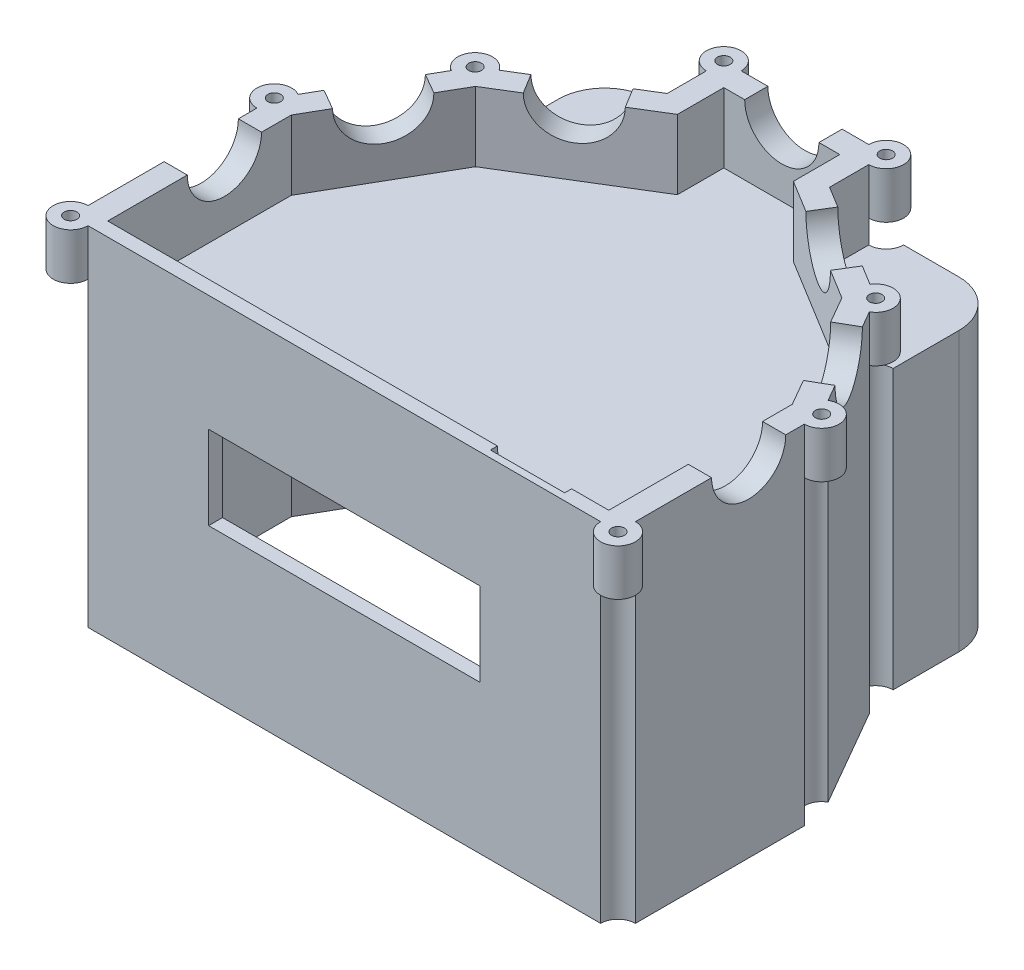
from build123d import *

# Parameters (mm, degrees)
BOSS_EXTRUDE2_DEPTH  = 15
BOSS_EXTRUDE3_DEPTH  = 5
SKETCH7_R            = 3.75
BOSS_EXTRUDE9_DEPTH  = 10
SKETCH9_R            = 1.375
CUT_EXTRUDE5_DEPTH   = 21
CUT_EXTRUDE9_REACH   = 131.287
SKETCH14_R           = 8
CUT_EXTRUDE11_REACH  = 105.053
SKETCH16_R           = 8
CUT_EXTRUDE12_REACH  = 131.287
SKETCH17_R           = 8
CUT_EXTRUDE13_REACH  = 121.393
SKETCH19_R           = 8
CUT_EXTRUDE14_REACH  = 121.393
SKETCH20_R           = 8
BOSS_EXTRUDE11_DEPTH = 55
FILLET1_R            = 10
SKETCH25_R           = 4
SKETCH25_R_2         = 1.4
BOSS_EXTRUDE12_DEPTH = 5
SKETCH24_R           = 3.75
CUT_EXTRUDE15_DEPTH  = 65
CUT_EXTRUDE17_REACH  = 105.053
SKETCH26_W           = 58.5
SKETCH26_H           = 18
BOSS_EXTRUDE13_REACH = 77
SKETCH27_R           = 4
SKETCH28_R           = 1.375
CUT_EXTRUDE18_DEPTH  = 25
SKETCH30_R           = 8
CUT_EXTRUDE19_DEPTH  = 122.75
SKETCH31_R           = 8
CUT_EXTRUDE20_DEPTH  = 1.5
SKETCH33_W           = 27
SKETCH33_H           = 4
CUT_EXTRUDE21_DEPTH  = 40
SKETCH35_R           = 1.25
SKETCH35_W           = 9
SKETCH35_H           = 9
CUT_EXTRUDE22_DEPTH  = 7.75


with BuildPart() as part:
    # Sketch1 → Boss-Extrude2 (new body)
    with BuildSketch(Plane(origin=(0, 0, 0), x_dir=(1, 0, 0), z_dir=(0, 1, 0))):
        Polygon((-43.178681761, 29.873916914), (-17.5, 45.604089113), (-17.5, 57.803420417), (17.5, 57.803420417), (17.5, 45.604089113), (43.178681761, 29.873916914), (59, 2.406681305), (59, -41.5), (-59, -41.5), (-59, 2.406681305), align=None)
        Polygon((39.481402229, 26.275231503), (12.5, 42.803420417), (12.5, 52.803420417), (-12.5, 52.803420417), (-12.5, 42.803420417), (-39.481402229, 26.275231503), (-54, 1.069636136), (-54, -38.5), (54, -38.5), (54, 1.069636136), align=None, mode=Mode.SUBTRACT)
    extrude(amount=BOSS_EXTRUDE2_DEPTH)

    # Sketch2 → Boss-Extrude3 (add)
    with BuildSketch(Plane.XZ):
        Polygon((-59, -2.406681305), (-59, 41.5), (59, 41.5), (59, -2.406681305), (43.178681761, -29.873916914), (43.178681761, -57.803420417), (-43.178681761, -57.803420417), (-43.178681761, -29.873916914), align=None)
    extrude(amount=BOSS_EXTRUDE3_DEPTH)

    # Sketch7 → Boss-Extrude9 (add)
    with BuildSketch(Plane(origin=(0, 15, 0), x_dir=(1, 0, 0), z_dir=(0, 1, 0))):
        with Locations((-59, -41.5)):
            Circle(SKETCH7_R)
        with Locations((-59, 2.406681305)):
            Circle(SKETCH7_R)
        with Locations((-43.178681761, 29.873916914)):
            Circle(SKETCH7_R)
        with Locations((-17.5, 57.803420417)):
            Circle(SKETCH7_R)
        with Locations((17.5, 57.803420417)):
            Circle(SKETCH7_R)
        with Locations((43.178681761, 29.873916914)):
            Circle(SKETCH7_R)
        with Locations((59, 2.406681305)):
            Circle(SKETCH7_R)
        with Locations((59, -41.5)):
            Circle(SKETCH7_R)
    extrude(amount=-BOSS_EXTRUDE9_DEPTH)

    # Sketch9 → Cut-Extrude5 (cut, through all)
    with BuildSketch(Plane(origin=(0, 15, 0), x_dir=(1, 0, 0), z_dir=(0, 1, 0))):
        with Locations((-59, -41.5)):
            Circle(SKETCH9_R)
        with Locations((-59, 2.406681305)):
            Circle(SKETCH9_R)
        with Locations((-17.5, 57.803420417)):
            Circle(SKETCH9_R)
        with Locations((43.178681761, 29.873916914)):
            Circle(SKETCH9_R)
        with Locations((17.5, 57.803420417)):
            Circle(SKETCH9_R)
        with Locations((-43.178681761, 29.873916914)):
            Circle(SKETCH9_R)
        with Locations((59, 2.406681305)):
            Circle(SKETCH9_R)
        with Locations((59, -41.5)):
            Circle(SKETCH9_R)
    extrude(amount=-CUT_EXTRUDE5_DEPTH, mode=Mode.SUBTRACT)

    # Sketch14 → Cut-Extrude9 (cut, up to next)
    with BuildSketch(Plane(origin=(-45.342387005, 0, -26.117529435), x_dir=(-0.499126718, 0, 0.866529006), z_dir=(-0.866529006, 0, -0.499126718)), mode=Mode.PRIVATE) as cut_extrude9_sk1:
        with Locations((11.514017709, 15)):
            Circle(SKETCH14_R)
    cut_extrude9_tool1 = extrude(cut_extrude9_sk1.sketch, amount=-CUT_EXTRUDE9_REACH, mode=Mode.PRIVATE) & part.part
    add(cut_extrude9_tool1.solids().sort_by_distance((-51.089341, 15, -16.140299))[0], mode=Mode.SUBTRACT)

    # Sketch16 → Cut-Extrude11 (cut, up to next)
    with BuildSketch(Plane(origin=(0, 0, -57.803420417), x_dir=(-1, 0, 0), z_dir=(0, 0, -1)), mode=Mode.PRIVATE) as cut_extrude11_sk1:
        with Locations((0, 15)):
            Circle(SKETCH16_R)
    cut_extrude11_tool1 = extrude(cut_extrude11_sk1.sketch, amount=-CUT_EXTRUDE11_REACH, mode=Mode.PRIVATE) & part.part
    add(cut_extrude11_tool1.solids().sort_by_distance((0, 15, -57.80342))[0], mode=Mode.SUBTRACT)

    # Sketch17 → Cut-Extrude12 (cut, up to next)
    with BuildSketch(Plane(origin=(45.342387005, 0, -26.117529435), x_dir=(-0.499126718, 0, -0.866529006), z_dir=(0.866529006, 0, -0.499126718)), mode=Mode.PRIVATE) as cut_extrude12_sk1:
        with Locations((-11.514017709, 15)):
            Circle(SKETCH17_R)
    cut_extrude12_tool1 = extrude(cut_extrude12_sk1.sketch, amount=-CUT_EXTRUDE12_REACH, mode=Mode.PRIVATE) & part.part
    add(cut_extrude12_tool1.solids().sort_by_distance((51.089341, 15, -16.140299))[0], mode=Mode.SUBTRACT)

    # Sketch19 → Cut-Extrude13 (cut, up to next)
    with BuildSketch(Plane(origin=(-25.088449392, 0, -40.955578852), x_dir=(-0.852725133, 0, 0.522359882), z_dir=(-0.522359882, 0, -0.852725133)), mode=Mode.PRIVATE) as cut_extrude13_sk1:
        with Locations((4.464611438, 15)):
            Circle(SKETCH19_R)
    cut_extrude13_tool1 = extrude(cut_extrude13_sk1.sketch, amount=-CUT_EXTRUDE13_REACH, mode=Mode.PRIVATE) & part.part
    add(cut_extrude13_tool1.solids().sort_by_distance((-28.895536, 15, -38.623445))[0], mode=Mode.SUBTRACT)

    # Sketch20 → Cut-Extrude14 (cut, up to next)
    with BuildSketch(Plane(origin=(25.088449392, 0, -40.955578852), x_dir=(-0.852725133, 0, -0.522359882), z_dir=(0.522359882, 0, -0.852725133)), mode=Mode.PRIVATE) as cut_extrude14_sk1:
        with Locations((-4.464611438, 15)):
            Circle(SKETCH20_R)
    cut_extrude14_tool1 = extrude(cut_extrude14_sk1.sketch, amount=-CUT_EXTRUDE14_REACH, mode=Mode.PRIVATE) & part.part
    add(cut_extrude14_tool1.solids().sort_by_distance((28.895536, 15, -38.623445))[0], mode=Mode.SUBTRACT)

    # Sketch21 → Boss-Extrude11 (add)
    with BuildSketch(Plane.XZ.offset(5)):
        Polygon((59, 41.5), (59, -2.406681305), (43.178681761, -29.873916914), (43.178681761, -57.803420417), (-43.178681761, -57.803420417), (-43.178681761, -29.873916914), (-59, -2.406681305), (-59, 41.5), align=None)
        Polygon((54, 38.5), (-54, 38.5), (-54, -1.069636136), (-38.178681761, -28.536871745), (-38.178681761, -52.803420417), (38.178681761, -52.803420417), (38.178681761, -28.536871745), (54, -1.069636136), align=None, mode=Mode.SUBTRACT)
    extrude(amount=BOSS_EXTRUDE11_DEPTH)

    # Fillet1
    fillet1_edges = [part.edges().sort_by_distance(p)[0] for p in [
        (43.178681761, -30, -57.803420417),
        (-43.178681761, -30, -57.803420417),
    ]]
    fillet(fillet1_edges, radius=FILLET1_R)

    # Sketch25 → Boss-Extrude12 (add)
    with BuildSketch(Plane(origin=(0, -5, 0), x_dir=(-1, 0, 0), z_dir=(0, -1, 0))):
        with Locations((-24.5, 40.5)):
            Circle(SKETCH25_R)
        with Locations((-24.5, 40.5)):
            Circle(SKETCH25_R_2, mode=Mode.SUBTRACT)
        with Locations((24.5, 40.5)):
            Circle(SKETCH25_R)
        with Locations((24.5, 40.5)):
            Circle(SKETCH25_R_2, mode=Mode.SUBTRACT)
        with Locations((24.5, -17.5)):
            Circle(SKETCH25_R)
        with Locations((24.5, -17.5)):
            Circle(SKETCH25_R_2, mode=Mode.SUBTRACT)
        with Locations((-24.5, -17.5)):
            Circle(SKETCH25_R)
        with Locations((-24.5, -17.5)):
            Circle(SKETCH25_R_2, mode=Mode.SUBTRACT)
    extrude(amount=BOSS_EXTRUDE12_DEPTH)

    # Sketch24 → Cut-Extrude15 (cut)
    with BuildSketch(Plane.XZ.offset(60)):
        with Locations((59, 41.5)):
            Circle(SKETCH24_R)
        with Locations((59, -2.406681305)):
            Circle(SKETCH24_R)
        with Locations((43.178681761, -29.873916914)):
            Circle(SKETCH24_R)
        with Locations((17.5, -57.803420417)):
            Circle(SKETCH24_R)
        with Locations((-17.5, -57.803420417)):
            Circle(SKETCH24_R)
        with Locations((-43.178681761, -29.873916914)):
            Circle(SKETCH24_R)
        with Locations((-59, -2.406681305)):
            Circle(SKETCH24_R)
        with Locations((-59, 41.5)):
            Circle(SKETCH24_R)
    extrude(amount=-CUT_EXTRUDE15_DEPTH, mode=Mode.SUBTRACT)

    # Sketch26 → Cut-Extrude17 (cut, up to next)
    with BuildSketch(Plane.XY.offset(41.5), mode=Mode.PRIVATE) as cut_extrude17_sk1:
        with Locations((0, -19)):
            Rectangle(SKETCH26_W, SKETCH26_H)
    cut_extrude17_tool1 = extrude(cut_extrude17_sk1.sketch, amount=-CUT_EXTRUDE17_REACH, mode=Mode.PRIVATE) & part.part
    add(cut_extrude17_tool1.solids().sort_by_distance((0, -19, 41.5))[0], mode=Mode.SUBTRACT)

    # Sketch27 → Boss-Extrude13 (add, up to next)
    with BuildSketch(Plane(origin=(0, -60, 0), x_dir=(-1, 0, 0), z_dir=(0, -1, 0)), mode=Mode.PRIVATE) as boss_extrude13_sk1:
        with Locations((-51.25, -35.75)):
            Circle(SKETCH27_R)
    boss_extrude13_tool1 = extrude(boss_extrude13_sk1.sketch, amount=-BOSS_EXTRUDE13_REACH, mode=Mode.PRIVATE) - part.part
    add(boss_extrude13_tool1.solids().sort_by_distance((51.25, -60, 35.75))[0])
    # Sketch27 → Boss-Extrude13 (add, up to next)
    with BuildSketch(Plane(origin=(0, -60, 0), x_dir=(-1, 0, 0), z_dir=(0, -1, 0)), mode=Mode.PRIVATE) as boss_extrude13_sk2:
        with Locations((-35.428681761, 50.053420417)):
            Circle(SKETCH27_R)
    boss_extrude13_tool2 = extrude(boss_extrude13_sk2.sketch, amount=-BOSS_EXTRUDE13_REACH, mode=Mode.PRIVATE) - part.part
    add(boss_extrude13_tool2.solids().sort_by_distance((35.428682, -60, -50.05342))[0])
    # Sketch27 → Boss-Extrude13 (add, up to next)
    with BuildSketch(Plane(origin=(0, -60, 0), x_dir=(-1, 0, 0), z_dir=(0, -1, 0)), mode=Mode.PRIVATE) as boss_extrude13_sk3:
        with Locations((35.428681761, 50.053420417)):
            Circle(SKETCH27_R)
    boss_extrude13_tool3 = extrude(boss_extrude13_sk3.sketch, amount=-BOSS_EXTRUDE13_REACH, mode=Mode.PRIVATE) - part.part
    add(boss_extrude13_tool3.solids().sort_by_distance((-35.428682, -60, -50.05342))[0])
    # Sketch27 → Boss-Extrude13 (add, up to next)
    with BuildSketch(Plane(origin=(0, -60, 0), x_dir=(-1, 0, 0), z_dir=(0, -1, 0)), mode=Mode.PRIVATE) as boss_extrude13_sk4:
        with Locations((51.25, -35.75)):
            Circle(SKETCH27_R)
    boss_extrude13_tool4 = extrude(boss_extrude13_sk4.sketch, amount=-BOSS_EXTRUDE13_REACH, mode=Mode.PRIVATE) - part.part
    add(boss_extrude13_tool4.solids().sort_by_distance((-51.25, -60, 35.75))[0])

    # Sketch28 → Cut-Extrude18 (cut)
    with BuildSketch(Plane(origin=(0, -60, 0), x_dir=(-1, 0, 0), z_dir=(0, -1, 0))):
        with Locations((-51.25, -35.75)):
            Circle(SKETCH28_R)
        with Locations((-35.428681761, 50.053420417)):
            Circle(SKETCH28_R)
        with Locations((35.428681761, 50.053420417)):
            Circle(SKETCH28_R)
        with Locations((51.25, -35.75)):
            Circle(SKETCH28_R)
    extrude(amount=-CUT_EXTRUDE18_DEPTH, mode=Mode.SUBTRACT)

    # Sketch30 → Cut-Extrude19 (cut, through all)
    with BuildSketch(Plane.ZY.offset(59)):
        with Locations((13.34, 15)):
            Circle(SKETCH30_R)
    extrude(amount=-CUT_EXTRUDE19_DEPTH, mode=Mode.SUBTRACT)

    # Sketch31 → Cut-Extrude20 (cut)
    with BuildSketch(Plane(origin=(0, 0, 38.5), x_dir=(-1, 0, 0), z_dir=(0, 0, -1))):
        with Locations((-38, 15)):
            Circle(SKETCH31_R)
    extrude(amount=-CUT_EXTRUDE20_DEPTH, mode=Mode.SUBTRACT)

    # Sketch33 → Cut-Extrude21 (cut)
    with BuildSketch(Plane.XZ.offset(60)):
        with Locations((0, -52.803420417)):
            Rectangle(SKETCH33_W, SKETCH33_H)
    extrude(amount=-CUT_EXTRUDE21_DEPTH, mode=Mode.SUBTRACT)

    # Sketch35 → Cut-Extrude22 (cut, through all)
    with BuildSketch(Plane.XY.offset(-54.803420417)):
        with Locations((10.5, -35.5)):
            Circle(SKETCH35_R)
        with Locations((-10.5, -35.5)):
            Circle(SKETCH35_R)
        with Locations((-10.5, -23)):
            Circle(SKETCH35_R)
        with Locations((10.5, -23)):
            Circle(SKETCH35_R)
        with Locations((0, -35.5)):
            Rectangle(SKETCH35_W, SKETCH35_H)
    extrude(amount=-CUT_EXTRUDE22_DEPTH, mode=Mode.SUBTRACT)


solid = part.part
